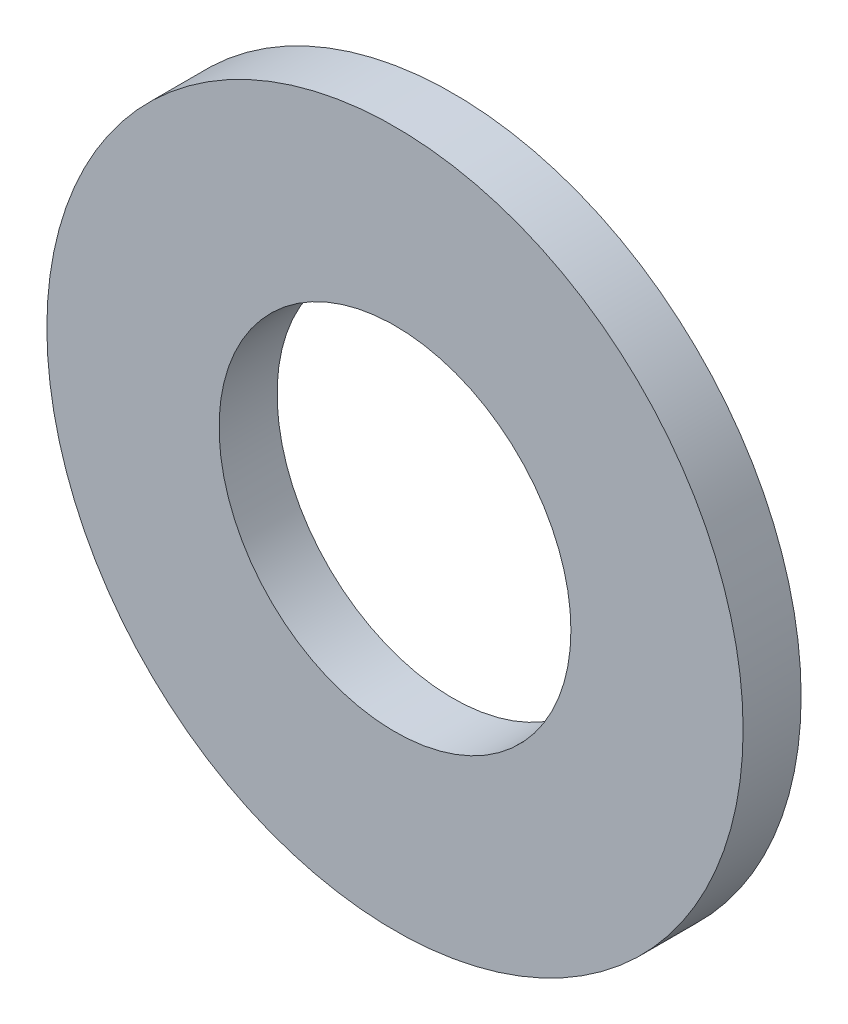
from build123d import *

# Parameters (mm, degrees)
SKETCH1_R      = 9.525
SKETCH1_R_2    = 4.8133
EXTRUDE1_DEPTH = 0.79375


with BuildPart() as part:
    # Sketch1 → Extrude1 (new body, symmetric)
    with BuildSketch(Plane.XY):
        Circle(SKETCH1_R)
        Circle(SKETCH1_R_2, mode=Mode.SUBTRACT)
    extrude(amount=EXTRUDE1_DEPTH, both=True)


solid = part.part
